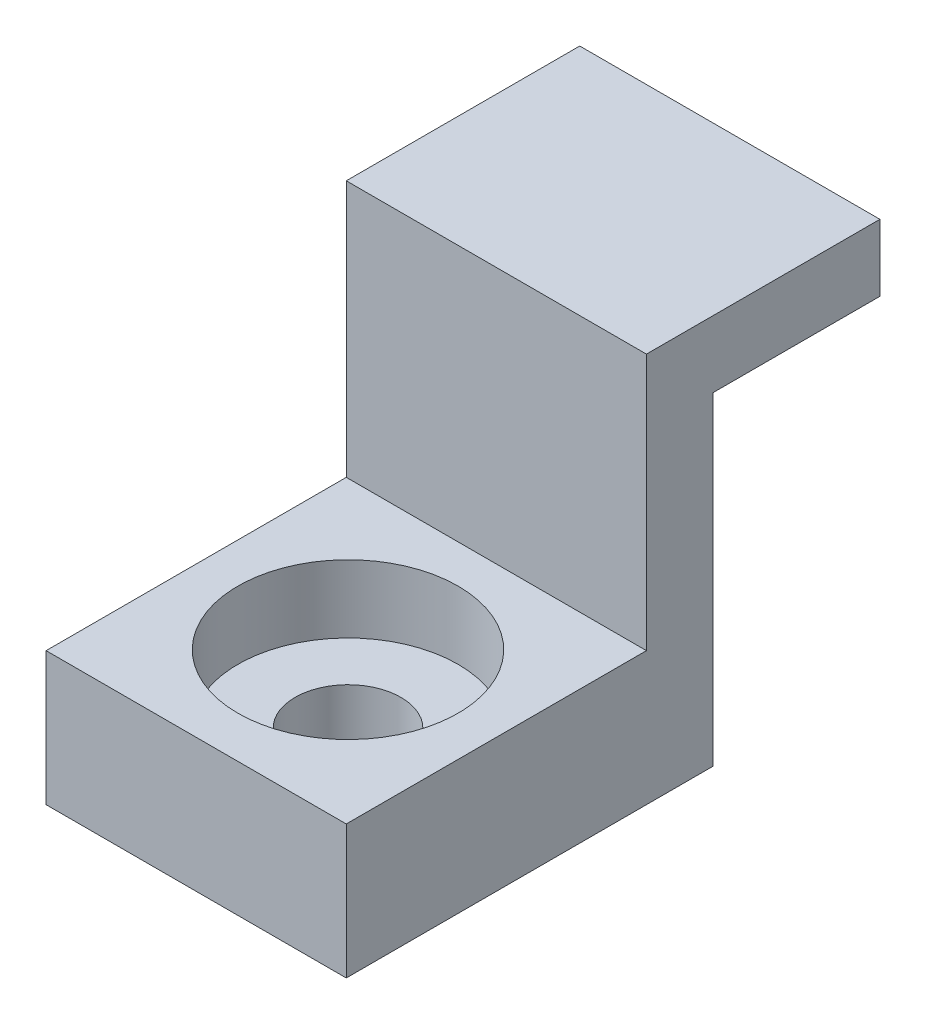
from build123d import *

# Parameters (mm, degrees)
SKETCH1_W                                           = 9
SKETCH1_H                                           = 11.7
BOSS_EXTRUDE1_DEPTH                                 = 2
SKETCH2_W                                           = 9
SKETCH2_H                                           = 2
BOSS_EXTRUDE2_DEPTH                                 = 5
SKETCH3_W                                           = 9
SKETCH3_H                                           = 4
BOSS_EXTRUDE3_DEPTH                                 = 9
CBORE_FOR_4_BINDING_HEAD_MACHINE_SCREW1_D           = 3.175
CBORE_FOR_4_BINDING_HEAD_MACHINE_SCREW1_CBORE_D     = 6.604
CBORE_FOR_4_BINDING_HEAD_MACHINE_SCREW1_CBORE_DEPTH = 2.032


with BuildPart() as part:
    # Sketch1 → Boss-Extrude1 (new body)
    with BuildSketch(Plane.XY):
        with Locations((-87.930083344, 0.6)):
            Rectangle(SKETCH1_W, SKETCH1_H)
    extrude(amount=BOSS_EXTRUDE1_DEPTH)

    # Sketch2 → Boss-Extrude2 (add)
    with BuildSketch(Plane(origin=(0, 0, 0), x_dir=(-1, 0, 0), z_dir=(0, 0, -1))):
        with Locations((87.930083344, 5.45)):
            Rectangle(SKETCH2_W, SKETCH2_H)
    extrude(amount=BOSS_EXTRUDE2_DEPTH)

    # Sketch3 → Boss-Extrude3 (add)
    with BuildSketch(Plane.XY.offset(2)):
        with Locations((-87.930083344, -3.25)):
            Rectangle(SKETCH3_W, SKETCH3_H)
    extrude(amount=BOSS_EXTRUDE3_DEPTH)

    # CBORE for #4 Binding Head Machine Screw1 (through all)
    with Locations(Plane(origin=(0, -1.25, 0), x_dir=(1, 0, 0), z_dir=(0, 1, 0))):
        with Locations((-87.930083344, -6.448155288)):
            CounterBoreHole(CBORE_FOR_4_BINDING_HEAD_MACHINE_SCREW1_D / 2, CBORE_FOR_4_BINDING_HEAD_MACHINE_SCREW1_CBORE_D / 2, CBORE_FOR_4_BINDING_HEAD_MACHINE_SCREW1_CBORE_DEPTH)


solid = part.part
